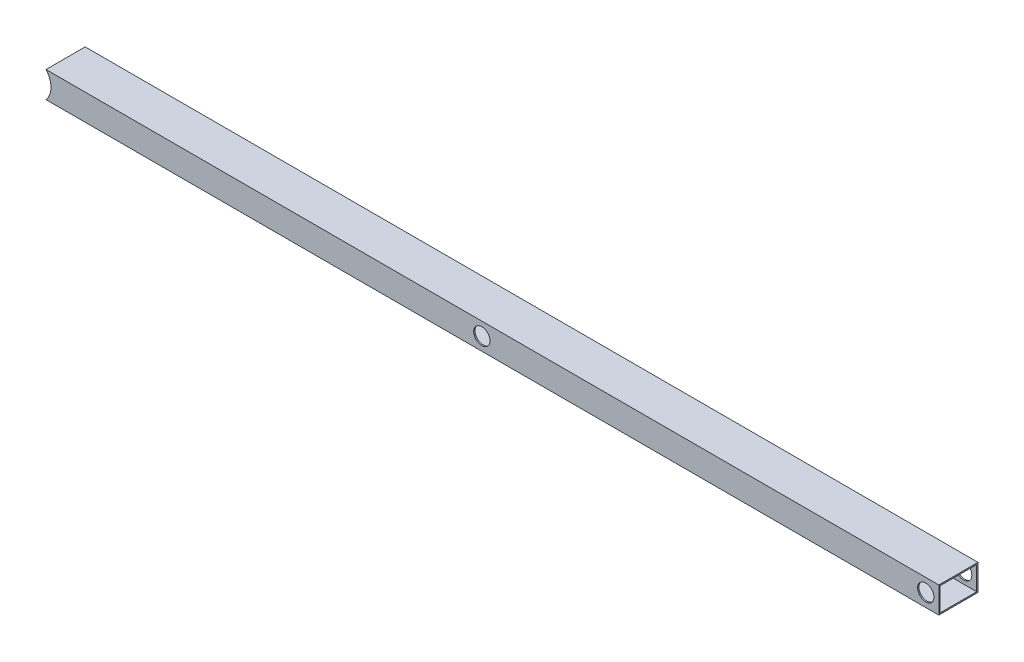
from build123d import *

# Parameters (mm, degrees)
SKETCH1_R           = 12.5
BOSS_EXTRUDE1_DEPTH = 30
SKETCH2_W           = 56
SKETCH2_H           = 36
CUT_EXTRUDE1_DEPTH  = 1368.639320225


with BuildPart() as part:
    # Sketch1 → Boss-Extrude1 (new body, symmetric)
    with BuildSketch(Plane.XY):
        with BuildLine():
            Line((700, -20), (700, 20))
            Line((700, 20), (-667.639320225, 20))
            ThreePointArc((-667.639320225, 20), (-661.974829231, 10.704662693), (-660, 0))
            ThreePointArc((-660, 0), (-661.974829231, -10.704662693), (-667.639320225, -20))
            Line((-667.639320225, -20), (700, -20))
        make_face()
        Circle(SKETCH1_R, mode=Mode.SUBTRACT)
        with Locations((680, 0)):
            Circle(SKETCH1_R, mode=Mode.SUBTRACT)
    extrude(amount=BOSS_EXTRUDE1_DEPTH, both=True)

    # Sketch2 → Cut-Extrude1 (cut, through all)
    with BuildSketch(Plane(origin=(700, 0, 0), x_dir=(0, 0, -1), z_dir=(1, 0, 0))):
        Rectangle(SKETCH2_W, SKETCH2_H)
    extrude(amount=-CUT_EXTRUDE1_DEPTH, mode=Mode.SUBTRACT)


solid = part.part
